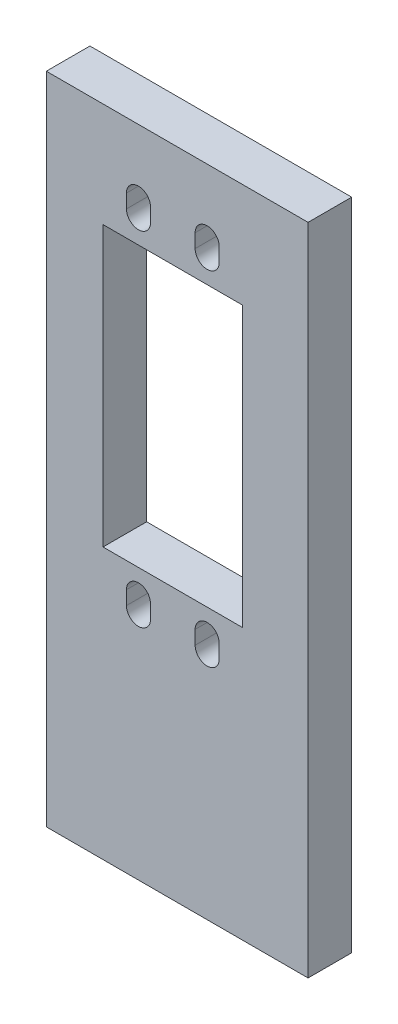
from build123d import *

# Parameters (mm, degrees)
SKETCH1_W           = 38.1
SKETCH1_H           = 95.25
BOSS_EXTRUDE1_DEPTH = 6.35
SKETCH2_W           = 20.32
SKETCH2_H           = 40.64
CUT_EXTRUDE1_DEPTH  = 6.35


with BuildPart() as part:
    # Sketch1 → Boss-Extrude1 (new body)
    with BuildSketch(Plane.XY):
        with Locations((19.05, 47.625)):
            Rectangle(SKETCH1_W, SKETCH1_H)
    extrude(amount=BOSS_EXTRUDE1_DEPTH)

    # Sketch2 → Cut-Extrude1 (cut)
    with BuildSketch(Plane(origin=(0, 0, 0), x_dir=(-1, 0, 0), z_dir=(0, 0, -1))):
        with Locations((-18.415, 59.725)):
            Rectangle(SKETCH2_W, SKETCH2_H)
        with BuildLine():
            Line((-25.165, 83.725), (-25.165, 85.725))
            ThreePointArc((-25.165, 85.725), (-23.415, 87.475), (-21.665, 85.725))
            Line((-21.665, 85.725), (-21.665, 83.725))
            ThreePointArc((-21.665, 83.725), (-23.415, 81.975), (-25.165, 83.725))
        make_face()
        with BuildLine():
            Line((-15.165, 83.725), (-15.165, 85.725))
            ThreePointArc((-15.165, 85.725), (-13.415, 87.475), (-11.665, 85.725))
            Line((-11.665, 85.725), (-11.665, 83.725))
            ThreePointArc((-11.665, 83.725), (-13.415, 81.975), (-15.165, 83.725))
        make_face()
        with BuildLine():
            Line((-21.665, 35.725), (-21.665, 33.725))
            ThreePointArc((-21.665, 33.725), (-23.415, 31.975), (-25.165, 33.725))
            Line((-25.165, 33.725), (-25.165, 35.725))
            ThreePointArc((-25.165, 35.725), (-23.415, 37.475), (-21.665, 35.725))
        make_face()
        with BuildLine():
            Line((-11.665, 35.725), (-11.665, 33.725))
            ThreePointArc((-11.665, 33.725), (-13.415, 31.975), (-15.165, 33.725))
            Line((-15.165, 33.725), (-15.165, 35.725))
            ThreePointArc((-15.165, 35.725), (-13.415, 37.475), (-11.665, 35.725))
        make_face()
    extrude(amount=-CUT_EXTRUDE1_DEPTH, mode=Mode.SUBTRACT)


solid = part.part
